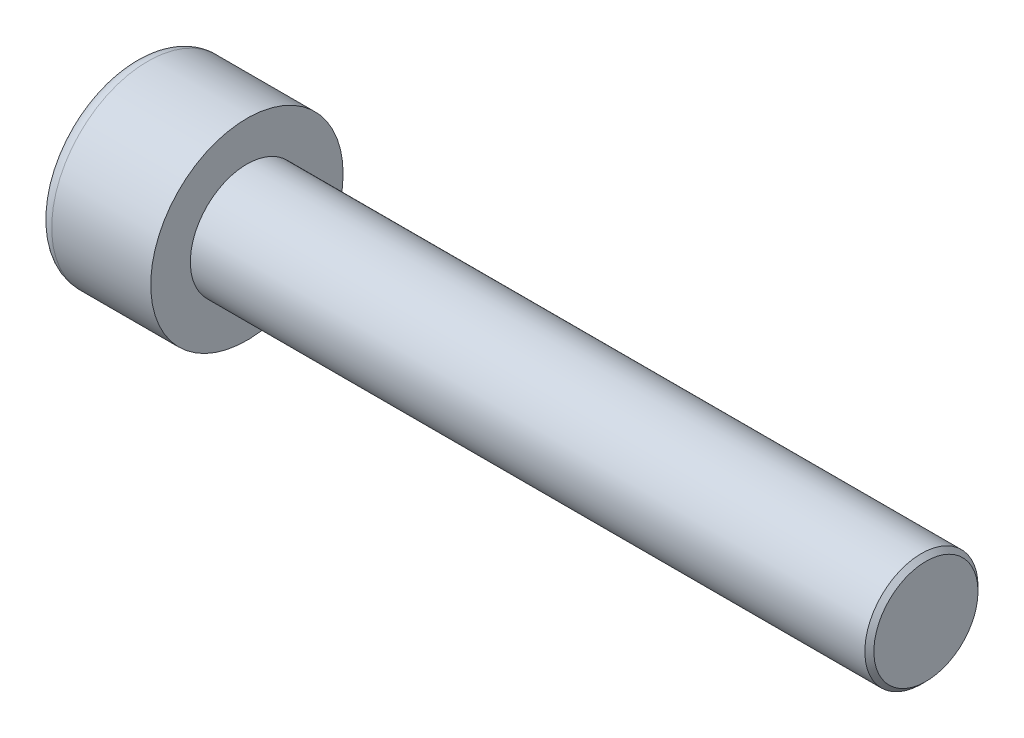
from build123d import *

# Parameters (mm, degrees)
SKETCH1_R           = 4.25
BASEHEAD_DEPTH      = 5
SKETCH2_R           = 2.5
BASEBODY_DEPTH      = 30
HEXAGONSOCKET_DEPTH = 2.5
TOPFILLET_R         = 0.625
CHAMFER1_SIZE       = 0.2


with BuildPart() as part:
    # Sketch1 → BaseHead (new body)
    with BuildSketch(Plane(origin=(0, 0, 0), x_dir=(0, 0, -1), z_dir=(1, 0, 0))):
        Circle(SKETCH1_R)
    extrude(amount=BASEHEAD_DEPTH)

    # Sketch2 → BaseBody (add)
    with BuildSketch(Plane(origin=(5, 0, 0), x_dir=(0, 0, -1), z_dir=(1, 0, 0))):
        Circle(SKETCH2_R)
    extrude(amount=BASEBODY_DEPTH)

    # Sketch3 → HexagonSocket (cut)
    with BuildSketch(Plane(origin=(0, 0, 0), x_dir=(0, 0, -1), z_dir=(1, 0, 0))):
        Polygon((2.309401077, 0), (1.154700538, 2), (-1.154700538, 2), (-2.309401077, 0), (-1.154700538, -2), (1.154700538, -2), align=None)
    extrude(amount=HEXAGONSOCKET_DEPTH, mode=Mode.SUBTRACT)

    # Sketch4 → Cut-Revolve1 (revolve, cut)
    with BuildSketch(Plane(origin=(-4.19613823, 0.75, 0), x_dir=(-1, 0, 0), z_dir=(0, 0, 1))):
        Polygon((-6.69613823, 2.75), (-7.850838768, 0.75), (-6.69613823, 0.75), align=None)
    revolve(axis=Axis((0.838992387, 0, 0), (-1, 0, 0)), mode=Mode.SUBTRACT)

    # TopFillet
    topfillet_edges = [part.edges().sort_by_distance(p)[0] for p in [
        (0, 0, 4.25),
    ]]
    fillet(topfillet_edges, radius=TOPFILLET_R)

    # Chamfer1
    chamfer1_edges = [part.edges().sort_by_distance(p)[0] for p in [
        (35, 0, 2.5),
    ]]
    chamfer(chamfer1_edges, length=CHAMFER1_SIZE)


solid = part.part
